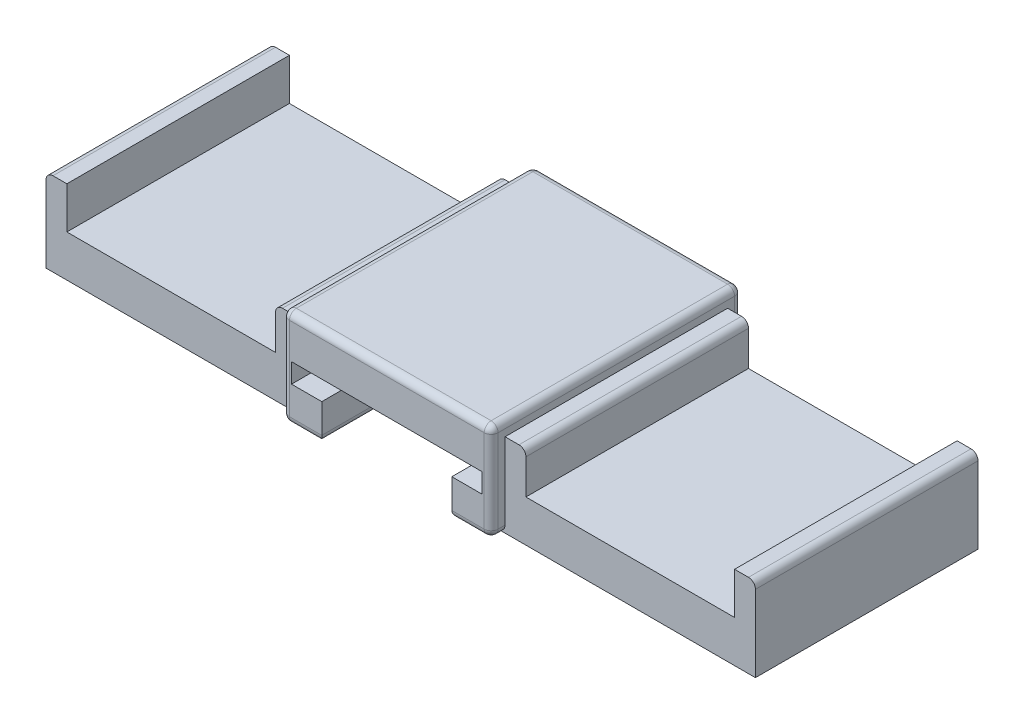
from build123d import *

# Parameters (mm, degrees)
SKETCH1_W           = 15
SKETCH1_H           = 18
BOSS_EXTRUDE1_DEPTH = 7
CUT_EXTRUDE1_DEPTH  = 14.2
SKETCH8_W           = 0.5
SKETCH8_H           = 2.6
CUT_EXTRUDE4_DEPTH  = 10
SKETCH9_W           = 16
SKETCH9_H           = 6
BOSS_EXTRUDE2_DEPTH = 18
SKETCH13_W          = 16
SKETCH13_H          = 6
BOSS_EXTRUDE3_DEPTH = 18
SKETCH14_W          = 15
SKETCH14_H          = 3
CUT_EXTRUDE5_DEPTH  = 32.55
FILLET1_R           = 0.5


with BuildPart() as part:
    # Sketch1 → Boss-Extrude1 (new body)
    with BuildSketch(Plane(origin=(0, 0, 0), x_dir=(1, 0, 0), z_dir=(0, 1, 0))):
        Rectangle(SKETCH1_W, SKETCH1_H)
    extrude(amount=BOSS_EXTRUDE1_DEPTH)

    # Sketch2 → Cut-Extrude1 (cut)
    with BuildSketch(Plane.XY.offset(9)):
        Polygon((-4.675, 2.6), (-4.675, 0), (-1.1, 0), (-1.1, 2.6), (-0.6, 2.6), (-0.6, 0), (0.6, 0), (0.6, 2.6), (1.1, 2.6), (1.1, 0), (4.675, 0), (4.675, 2.6), (6.85, 2.6), (6.85, 4), (-6.85, 4), (-6.85, 2.6), align=None)
    extrude(amount=-CUT_EXTRUDE1_DEPTH, mode=Mode.SUBTRACT)

    # Sketch8 → Cut-Extrude4 (cut)
    with BuildSketch(Plane.XY.offset(9)):
        with Locations((-0.85, 1.3)):
            Rectangle(SKETCH8_W, SKETCH8_H)
        with Locations((0.85, 1.3)):
            Rectangle(SKETCH8_W, SKETCH8_H)
    extrude(amount=-CUT_EXTRUDE4_DEPTH, mode=Mode.SUBTRACT)

    # Sketch9 → Boss-Extrude2 (add)
    with BuildSketch(Plane.ZY.offset(7.5)):
        with Locations((0, 3)):
            Rectangle(SKETCH9_W, SKETCH9_H)
    extrude(amount=BOSS_EXTRUDE2_DEPTH)

    # Sketch13 → Boss-Extrude3 (add)
    with BuildSketch(Plane(origin=(7.5, 0, 0), x_dir=(0, 0, -1), z_dir=(1, 0, 0))):
        with Locations((0, 3)):
            Rectangle(SKETCH13_W, SKETCH13_H)
    extrude(amount=BOSS_EXTRUDE3_DEPTH)

    # Sketch14 → Cut-Extrude5 (cut)
    with BuildSketch(Plane.XY.offset(9)):
        with Locations((16.5, 4.5)):
            Rectangle(SKETCH14_W, SKETCH14_H)
        with Locations((-16.5, 4.5)):
            Rectangle(SKETCH14_W, SKETCH14_H)
    extrude(amount=-CUT_EXTRUDE5_DEPTH, mode=Mode.SUBTRACT)

    # Fillet1
    fillet1_edges = [part.edges().sort_by_distance(p)[0] for p in [
        (-7.5, 0, 8.5),
        (-25.5, 6, 0),
        (7.5, 0, -8.5),
        (25.5, 6, 0),
        (-7.5, 7, 0),
        (9, 6, 0),
        (-9, 6, 0),
        (6.0875, 0, 9),
        (0, 7, 9),
        (4.675, 0, 1.9),
        (-4.675, 0, 1.9),
        (7.5, 7, 0),
        (-6.0875, 0, 9),
        (-7.5, 0, -8.5),
        (0, 0, -9),
        (7.5, 0, 8.5),
        (7.5, 3.5, 9),
        (-7.5, 3.5, 9),
        (-7.5, 3.5, -9),
        (7.5, 3.5, -9),
        (0, 7, -9),
    ]]
    fillet(fillet1_edges, radius=FILLET1_R)


solid = part.part
